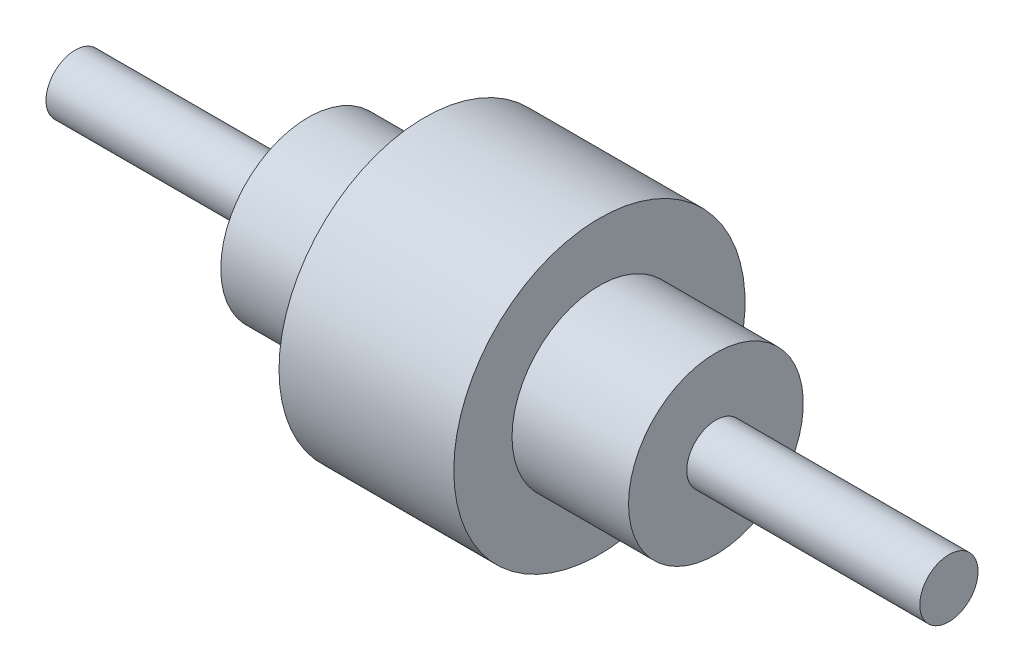
from build123d import *


with BuildPart() as part:
    # Sketch1 → Revolve1 (revolve)
    with BuildSketch(Plane.XY, mode=Mode.PRIVATE) as revolve1_sk:
        Polygon((0, 10), (0, 0), (300, 0), (300, 10), (220, 10), (220, 30), (180, 30), (180, 50), (120, 50), (120, 30), (80, 30), (80, 10), align=None)
    revolve(revolve1_sk.sketch.rotate(Axis((0, 0, 0), (1, 0, 0)), 90), axis=Axis((0, 0, 0), (1, 0, 0)))  # turned: the seam where the file's is


solid = part.part
